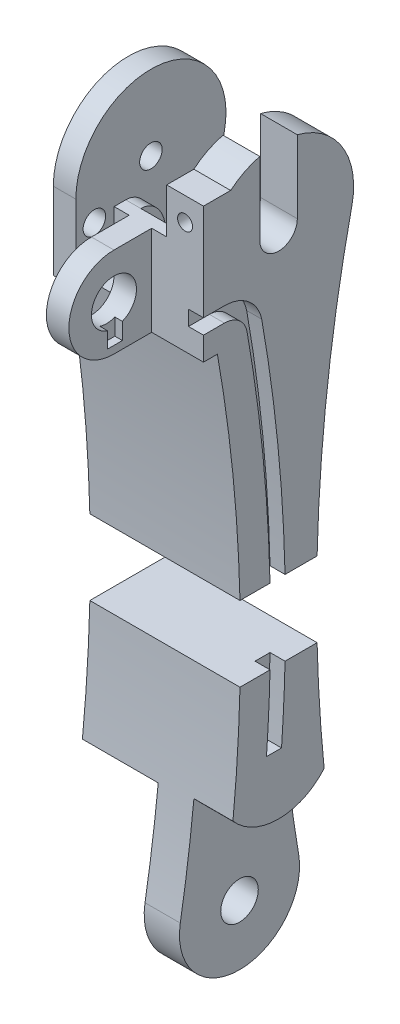
from build123d import *

# Parameters (mm, degrees)
SKETCH1_R                = 1.5
SKETCH1_R_2              = 2.5
BOSS_EXTRUDE1_DEPTH      = 20
SKETCH2_W                = 8.1
SKETCH2_H                = 20
SKETCH2_W_2              = 5.2
SKETCH2_W_3              = 5.1
CUT_EXTRUDE1_DEPTH       = 20
CUT_EXTRUDE1_DEPTH_BACK  = 20
CUT_EXTRUDE2_DEPTH       = 9
BOSS_EXTRUDE2_DEPTH      = 11.9
SKETCH5_R                = 3
BOSS_EXTRUDE3_DEPTH      = 5
CUT_EXTRUDE6_DEPTH       = 1
SKETCH13_R               = 2.5
CUT_EXTRUDE7_DEPTH       = 4
BOSS_EXTRUDE4_DEPTH      = 3
CUT_EXTRUDE9_DEPTH       = 3
SKETCH17_W               = 9
SKETCH17_H               = 3.569322199
CUT_EXTRUDE11_DEPTH      = 3
SKETCH18_W               = 5.770974844
SKETCH18_H               = 0.772936936
BOSS_EXTRUDE5_DEPTH      = 6.9
BOSS_EXTRUDE5_DEPTH_BACK = 1
SKETCH19_W               = 5.1
SKETCH19_H               = 16.397725614
CUT_EXTRUDE12_DEPTH      = 0.301495
SKETCH20_W               = 5
SKETCH20_H               = 12.419235667
CUT_EXTRUDE13_DEPTH      = 10
BOSS_EXTRUDE6_DEPTH      = 2
SKETCH23_W               = 4.9
SKETCH23_H               = 6
BOSS_EXTRUDE7_DEPTH      = 4
SKETCH22_R               = 1
CUT_EXTRUDE15_DEPTH      = 8
BOSS_EXTRUDE8_DEPTH      = 2
SKETCH14_R               = 1.5
CUT_EXTRUDE8_DEPTH       = 10.1
CUT_EXTRUDE17_DEPTH      = 8.1
CUT_EXTRUDE17_DEPTH_BACK = 2
CUT_EXTRUDE18_DEPTH      = 2
CUT_EXTRUDE20_DEPTH      = 5.2
SKETCH30_W               = 6.9
SKETCH30_H               = 20
CUT_EXTRUDE21_DEPTH      = 0.283797
CUT_EXTRUDE22_REACH      = 91.699
SKETCH31_W               = 2
SKETCH31_H               = 11.022421386
CUT_EXTRUDE23_DEPTH      = 7
CUT_EXTRUDE24_DEPTH      = 21


with BuildPart() as part:
    # Sketch1 → Boss-Extrude1 (new body)
    with BuildSketch(Plane(origin=(0, 0, 0), x_dir=(0, 0, -1), z_dir=(1, 0, 0))):
        with BuildLine():
            ThreePointArc((9.765353557, 20.116545894), (0, 32.270117322), (-9.765353557, 20.116545894))
            ThreePointArc((-9.765353557, 20.116545894), (-5.132645827, -18.047253777), (-7.88740095, -56.392382678))
            ThreePointArc((-7.88740095, -56.392382678), (0, -65.729882678), (7.88740095, -56.392382678))
            ThreePointArc((7.88740095, -56.392382678), (5.132645827, -18.047253777), (9.765353557, 20.116545894))
        make_face()
        with Locations((0, 22.270117322)):
            Circle(SKETCH1_R, mode=Mode.SUBTRACT)
        with Locations((0, -57.729882678)):
            Circle(SKETCH1_R_2, mode=Mode.SUBTRACT)
    extrude(amount=BOSS_EXTRUDE1_DEPTH)

    # Sketch2 → Cut-Extrude1 (cut, two sides)
    with BuildSketch(Plane.XY) as cut_extrude1_sk:
        with Locations((4.05, -55.729882678)):
            Rectangle(SKETCH2_W, SKETCH2_H)
        with Locations((17.4, -55.729882678)):
            Rectangle(SKETCH2_W_2, SKETCH2_H)
        with Locations((5.55, 22.270117322)):
            Rectangle(SKETCH2_W_3, SKETCH2_H)
    extrude(amount=CUT_EXTRUDE1_DEPTH, mode=Mode.SUBTRACT)
    extrude(cut_extrude1_sk.sketch, amount=-CUT_EXTRUDE1_DEPTH_BACK, mode=Mode.SUBTRACT)

    # Sketch3 → Cut-Extrude2 (cut)
    with BuildSketch(Plane.ZY.offset(-8.1)):
        with BuildLine():
            Line((8.5, 22.270117322), (8.5, 40.909533312))
            Line((8.5, 40.909533312), (-17.52872033, 40.909533312))
            Line((-17.52872033, 40.909533312), (-17.52872033, 13.770117322))
            Line((-17.52872033, 13.770117322), (0, 13.770117322))
            ThreePointArc((0, 13.770117322), (6.01040764, 16.259709682), (8.5, 22.270117322))
        make_face()
    extrude(amount=-CUT_EXTRUDE2_DEPTH, mode=Mode.SUBTRACT)

    # Sketch4 → Boss-Extrude2 (add, through all)
    with BuildSketch(Plane.ZY.offset(-8.1)):
        Polygon((8.5, 27.537944199), (8.283796844, 12.741558936), (10.283796844, 12.741558936), (10.283796844, 27.537944199), align=None)
    extrude(amount=-BOSS_EXTRUDE2_DEPTH)

    # Sketch5 → Boss-Extrude3 (add)
    with BuildSketch(Plane.ZY.offset(-8.1)):
        with BuildLine():
            Line((8.145156861, 11.968622), (8.447845456, 23.968622))
            Line((8.447845456, 23.968622), (9.854698466, 23.968622))
            Line((9.854698466, 23.968622), (15.022421386, 23.968622))
            ThreePointArc((15.022421386, 23.968622), (21.022421386, 17.968622), (15.022421386, 11.968622))
            Line((15.022421386, 11.968622), (8.145156861, 11.968622))
        make_face()
        with Locations((15.022421386, 17.968622)):
            Circle(SKETCH5_R, mode=Mode.SUBTRACT)
    extrude(amount=-BOSS_EXTRUDE3_DEPTH)

    # Sketch12 → Cut-Extrude6 (cut)
    with BuildSketch(Plane(origin=(13.1, 0, 0), x_dir=(0, 0, -1), z_dir=(1, 0, 0))):
        Polygon((-13.902900694, 14.968622), (-13.902900694, 12.968622), (-15.902900694, 12.968622), (-15.902900694, 14.968622), (-15.902900694, 15.294296094), (-13.902900694, 15.294296094), align=None)
    extrude(amount=-CUT_EXTRUDE6_DEPTH, mode=Mode.SUBTRACT)

    # Sketch13 → Cut-Extrude7 (cut)
    with BuildSketch(Plane.ZY.offset(-17.1)):
        with Locations((0, 22.270117322)):
            Circle(SKETCH13_R)
    extrude(amount=-CUT_EXTRUDE7_DEPTH, mode=Mode.SUBTRACT)

    # Sketch15 → Boss-Extrude4 (add)
    with BuildSketch(Plane.ZY):
        Polygon((10, 22.270117322), (10, 11.968622), (8.145156861, 11.968622), (7.595672539, 11.968622), align=None)
    extrude(amount=-BOSS_EXTRUDE4_DEPTH)

    # Sketch16 → Cut-Extrude9 (cut)
    with BuildSketch(Plane(origin=(20, 0, 0), x_dir=(0, 0, -1), z_dir=(1, 0, 0))):
        with BuildLine():
            Line((-10.283796844, 23.968622), (-9.854698466, 23.968622))
            ThreePointArc((-9.854698466, 23.968622), (-9.349264901, 25.818531871), (-8.5, 27.537944199))
            Line((-8.5, 27.537944199), (-10.283796844, 27.537944199))
            Line((-10.283796844, 27.537944199), (-10.283796844, 23.968622))
        make_face()
    extrude(amount=-CUT_EXTRUDE9_DEPTH, mode=Mode.SUBTRACT)

    # Sketch17 → Cut-Extrude11 (cut)
    with BuildSketch(Plane.XY.offset(10.283796844)):
        with Locations((12.6, 25.7532831)):
            Rectangle(SKETCH17_W, SKETCH17_H)
    extrude(amount=-CUT_EXTRUDE11_DEPTH, mode=Mode.SUBTRACT)

    # Sketch18 → Boss-Extrude5 (add, two sides)
    with BuildSketch(Plane(origin=(13.1, 0, 0), x_dir=(0, 0, -1), z_dir=(1, 0, 0))) as boss_extrude5_sk:
        with Locations((-7.398309422, 12.355090468)):
            Rectangle(SKETCH18_W, SKETCH18_H)
    extrude(amount=BOSS_EXTRUDE5_DEPTH)
    extrude(boss_extrude5_sk.sketch, amount=-BOSS_EXTRUDE5_DEPTH_BACK)

    # Sketch19 → Cut-Extrude12 (cut)
    with BuildSketch(Plane(origin=(0, 12.270117322, 0), x_dir=(1, 0, 0), z_dir=(0, 1, 0))):
        with Locations((5.55, 0)):
            Rectangle(SKETCH19_W, SKETCH19_H)
    extrude(amount=-CUT_EXTRUDE12_DEPTH, mode=Mode.SUBTRACT)

    # Sketch20 → Cut-Extrude13 (cut)
    with BuildSketch(Plane.ZY.offset(-17.1)):
        with Locations((0, 28.479735156)):
            Rectangle(SKETCH20_W, SKETCH20_H)
    extrude(amount=-CUT_EXTRUDE13_DEPTH, mode=Mode.SUBTRACT)

    # Sketch21 → Boss-Extrude6 (add)
    with BuildSketch(Plane.ZY.offset(-17.1)):
        with BuildLine():
            Line((-8.473151119, 13.770117322), (0.278481736, 12.273995678))
            ThreePointArc((0.278481736, 12.273995678), (9.936881703, 21.148341047), (2.5, 31.952575688))
            Line((2.5, 31.952575688), (2.5, 22.270117322))
            ThreePointArc((2.5, 22.270117322), (0, 19.770117322), (-2.5, 22.270117322))
            Line((-2.5, 22.270117322), (-2.5, 31.952575688))
            ThreePointArc((-2.5, 31.952575688), (-8.522477621, 27.501501002), (-9.765353557, 20.116545894))
            ThreePointArc((-9.765353557, 20.116545894), (-9.093560923, 16.948562662), (-8.473151119, 13.770117322))
        make_face()
    extrude(amount=BOSS_EXTRUDE6_DEPTH)

    # Sketch23 → Boss-Extrude7 (add)
    with BuildSketch(Plane.XY.offset(10.283796844)):
        with Locations((17.55, 26.968622)):
            Rectangle(SKETCH23_W, SKETCH23_H)
    extrude(amount=-BOSS_EXTRUDE7_DEPTH)

    # Sketch22 → Cut-Extrude15 (cut)
    with BuildSketch(Plane.XY.offset(10.283796844)):
        with Locations((17.55, 26.870117322)):
            Circle(SKETCH22_R)
    extrude(amount=-CUT_EXTRUDE15_DEPTH, mode=Mode.SUBTRACT)

    # Sketch24 → Boss-Extrude8 (add)
    with BuildSketch(Plane.ZY.offset(-8.1)):
        with BuildLine():
            Line((5.147845456, 19.737443909), (5.147845456, 15.506265819))
            Line((5.147845456, 15.506265819), (8.447845456, 15.506265819))
            Line((8.447845456, 15.506265819), (8.447845456, 23.968622))
            add(Edge.make_bspline(
                [(8.447845456, 23.968622), (5.147845456, 23.968622), (5.147845456, 19.737443909)],
                knots=[3.141592654, 3.141592654, 3.141592654, 4.71238898, 4.71238898, 4.71238898], degree=2, weights=[1, 0.707106781, 1]))
        make_face()
    extrude(amount=-BOSS_EXTRUDE8_DEPTH)

    # Sketch14 → Cut-Extrude8 (cut)
    with BuildSketch(Plane.ZY):
        with Locations((7.532575614, 18.331804915)):
            Circle(SKETCH14_R)
    extrude(amount=-CUT_EXTRUDE8_DEPTH, mode=Mode.SUBTRACT)

    # Sketch25 → Cut-Extrude17 (cut, two sides)
    with BuildSketch(Plane.ZY.offset(-8.1)) as cut_extrude17_sk:
        with BuildLine():
            Line((12, -45.729882678), (8.346153846, -36.960651908))
            ThreePointArc((8.346153846, -36.960651908), (6.973852263, -42.37911752), (2.5, -45.729882678))
            Line((2.5, -45.729882678), (2.5, -53.227383372))
            ThreePointArc((2.5, -53.227383372), (0, -62.879882678), (-2.5, -53.227383372))
            Line((-2.5, -53.227383372), (-2.5, -45.729882678))
            ThreePointArc((-2.5, -45.729882678), (-6.973852263, -42.37911752), (-8.346153846, -36.960651908))
            Line((-8.346153846, -36.960651908), (-12, -45.729882678))
            Line((-12, -45.729882678), (-12, -57.729882678))
            ThreePointArc((-12, -57.729882678), (0, -69.729882678), (12, -57.729882678))
            Line((12, -57.729882678), (12, -45.729882678))
        make_face()
    extrude(amount=CUT_EXTRUDE17_DEPTH, mode=Mode.SUBTRACT)
    extrude(cut_extrude17_sk.sketch, amount=-CUT_EXTRUDE17_DEPTH_BACK, mode=Mode.SUBTRACT)

    # Sketch26 → Cut-Extrude18 (cut)
    with BuildSketch(Plane(origin=(20, 0, 0), x_dir=(0, 0, -1), z_dir=(1, 0, 0))):
        with BuildLine():
            Line((-7.209968303, 15.085404497), (-10.283796844, 15.085404497))
            Line((-10.283796844, 15.085404497), (-10.283796844, 17.085404497))
            Line((-10.283796844, 17.085404497), (-7.209968303, 17.085404497))
            ThreePointArc((-7.209968303, 17.085404497), (-4.010444351, 15.949526558), (-2.243391617, 13.050441039))
            ThreePointArc((-2.243391617, 13.050441039), (0.649659998, -12.257973546), (0.397031114, -37.729953741))
            Line((0.397031114, -37.729953741), (-1.608183929, -37.729953741))
            ThreePointArc((-1.608183929, -37.729953741), (-1.343036313, -12.450773719), (-4.206611504, 12.667092093))
            ThreePointArc((-4.206611504, 12.667092093), (-5.281990934, 14.405678614), (-7.209968303, 15.085404497))
        make_face()
    extrude(amount=-CUT_EXTRUDE18_DEPTH, mode=Mode.SUBTRACT)

    # Sketch29 → Cut-Extrude20 (cut)
    with BuildSketch(Plane(origin=(20, 0, 0), x_dir=(0, 0, -1), z_dir=(1, 0, 0))):
        with BuildLine():
            Line((8, -37.729882678), (8.140336581, -37.729882678))
            Line((8.140336581, -37.729882678), (8.140336581, -45.937498976))
            Line((8.140336581, -45.937498976), (-15.754893946, -45.937498976))
            Line((-15.754893946, -45.937498976), (-15.754893946, -37.729882678))
            Line((-15.754893946, -37.729882678), (-8, -37.729882678))
            ThreePointArc((-8, -37.729882678), (0, -45.729882678), (8, -37.729882678))
        make_face()
    extrude(amount=-CUT_EXTRUDE20_DEPTH, mode=Mode.SUBTRACT)

    # Sketch30 → Cut-Extrude21 (cut)
    with BuildSketch(Plane.XY.offset(10.283796844)):
        with Locations((16.55, 21.968622)):
            Rectangle(SKETCH30_W, SKETCH30_H)
    extrude(amount=-CUT_EXTRUDE21_DEPTH, mode=Mode.SUBTRACT)

    # Sketch31 → Cut-Extrude22 (cut, up to next)
    with BuildSketch(Plane(origin=(0, 23.968622, 0), x_dir=(1, 0, 0), z_dir=(0, 1, 0)), mode=Mode.PRIVATE) as cut_extrude22_sk1:
        with Locations((9.1, -15.511210693)):
            Rectangle(SKETCH31_W, SKETCH31_H)
    cut_extrude22_tool1 = extrude(cut_extrude22_sk1.sketch, amount=-CUT_EXTRUDE22_REACH, mode=Mode.PRIVATE) & part.part
    add(cut_extrude22_tool1.solids().sort_by_distance((9.1, 23.968622, 15.511211))[0], mode=Mode.SUBTRACT)

    # Sketch32 → Cut-Extrude23 (cut)
    with BuildSketch(Plane.ZY.offset(-8.1)):
        Polygon((-8.473151119, 13.770117322), (-8.473151119, 5.401068454), (5.147845456, 15.506265819), align=None)
    extrude(amount=-CUT_EXTRUDE23_DEPTH, mode=Mode.SUBTRACT)

    # Sketch33 → Cut-Extrude24 (cut, through all)
    with BuildSketch(Plane(origin=(20, 0, 0), x_dir=(0, 0, -1), z_dir=(1, 0, 0))):
        Polygon((-9.30475326, -22.954882678), (-9.30475326, -27.954882678), (8.892389241, -27.954882678), (8.892389241, -22.954882678), (8.892389241, -17.954882678), (-9.30475326, -17.954882678), align=None)
    extrude(amount=-CUT_EXTRUDE24_DEPTH, mode=Mode.SUBTRACT)


solid = part.part
